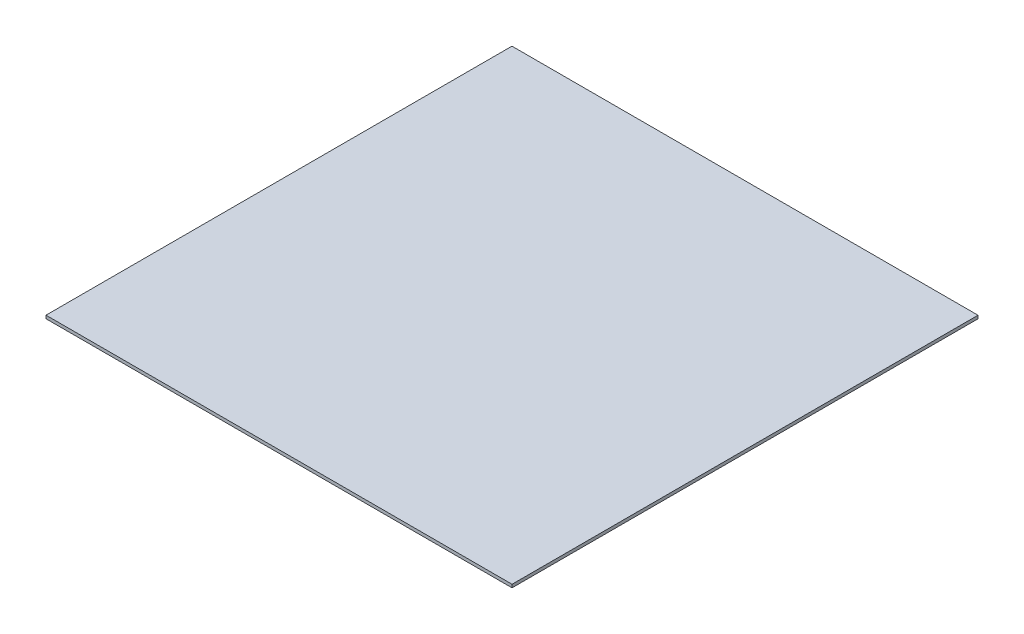
from build123d import *

# Parameters (mm, degrees)
SKETCH1_W           = 298.16
SKETCH1_H           = 298.1
BOSS_EXTRUDE1_DEPTH = 2


with BuildPart() as part:
    # Sketch1 → Boss-Extrude1 (new body)
    with BuildSketch(Plane(origin=(0, 0, 0), x_dir=(1, 0, 0), z_dir=(0, 1, 0))):
        Rectangle(SKETCH1_W, SKETCH1_H)
    extrude(amount=BOSS_EXTRUDE1_DEPTH)


solid = part.part
